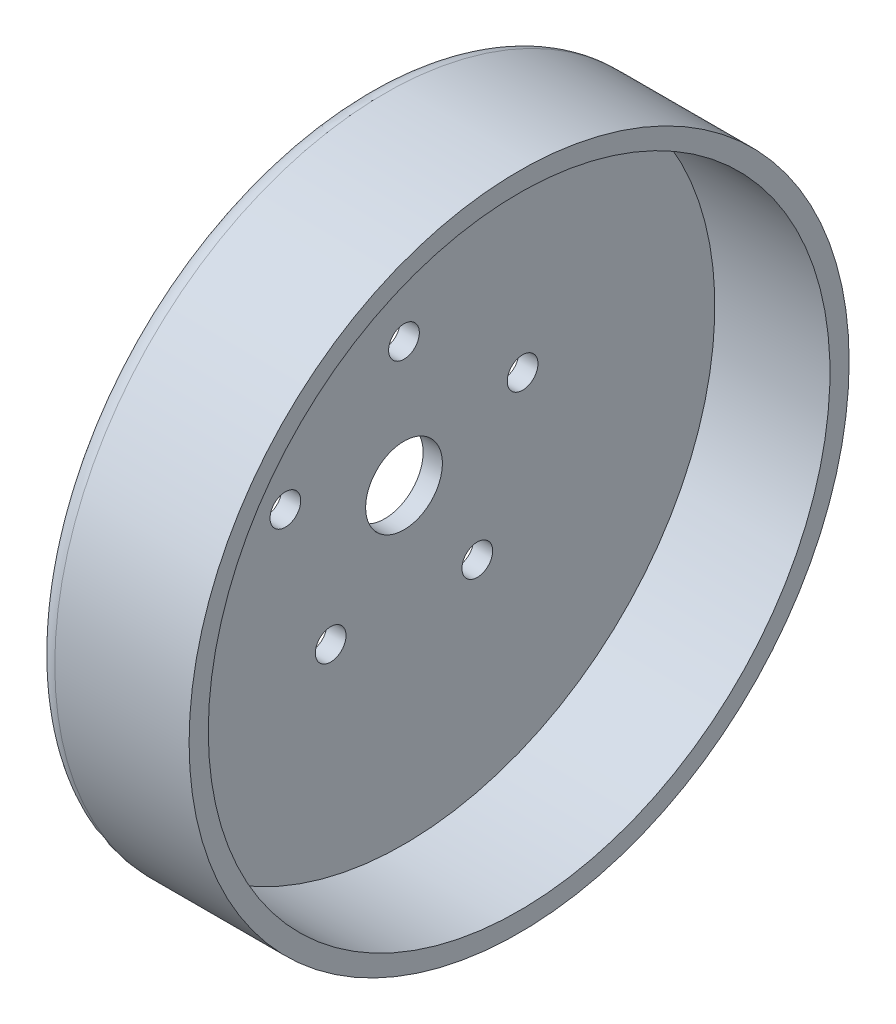
from build123d import *

# Parameters (mm, degrees)
FILLET1_R          = 5
SKETCH2_R          = 45
CUT_EXTRUDE1_DEPTH = 5
SKETCH3_R          = 10
CUT_EXTRUDE2_DEPTH = 41
CUT_EXTRUDE3_REACH = 37
SKETCH4_R          = 4


with BuildPart() as part:
    # Sketch1 → Revolve1 (revolve)
    with BuildSketch(Plane.XY):
        Polygon((0, 0), (0, 81), (30, 81), (30, 86), (-10, 86), (-10, 0), align=None)
    revolve(axis=Axis((-10, 0, 0), (1, 0, 0)))

    # Fillet1
    fillet1_edges = [part.edges().sort_by_distance(p)[0] for p in [
        (-10, -86, 0),
    ]]
    fillet(fillet1_edges, radius=FILLET1_R)

    # Sketch2 → Cut-Extrude1 (cut)
    with BuildSketch(Plane.ZY.offset(10)):
        Circle(SKETCH2_R)
    extrude(amount=-CUT_EXTRUDE1_DEPTH, mode=Mode.SUBTRACT)

    # Sketch3 → Cut-Extrude2 (cut, through all)
    with BuildSketch(Plane.ZY.offset(10)):
        Circle(SKETCH3_R)
    extrude(amount=-CUT_EXTRUDE2_DEPTH, mode=Mode.SUBTRACT)

    # Sketch4 → Cut-Extrude3 (cut, up to next)
    with BuildSketch(Plane.ZY.offset(5), mode=Mode.PRIVATE) as cut_extrude3_sk1:
        with Locations((0, 32.5)):
            Circle(SKETCH4_R)
    cut_extrude3_tool1 = extrude(cut_extrude3_sk1.sketch, amount=-CUT_EXTRUDE3_REACH, mode=Mode.PRIVATE) & part.part
    add(cut_extrude3_tool1.solids().sort_by_distance((-5, 32.5, 0))[0], mode=Mode.SUBTRACT)
    # Sketch4 → Cut-Extrude3 (cut, up to next)
    with BuildSketch(Plane.ZY.offset(5), mode=Mode.PRIVATE) as cut_extrude3_sk2:
        with Locations((30.90933678, 10.043052317)):
            Circle(SKETCH4_R)
    cut_extrude3_tool2 = extrude(cut_extrude3_sk2.sketch, amount=-CUT_EXTRUDE3_REACH, mode=Mode.PRIVATE) & part.part
    add(cut_extrude3_tool2.solids().sort_by_distance((-5, 10.043052, 30.909337))[0], mode=Mode.SUBTRACT)
    # Sketch4 → Cut-Extrude3 (cut, up to next)
    with BuildSketch(Plane.ZY.offset(5), mode=Mode.PRIVATE) as cut_extrude3_sk3:
        with Locations((19.1030207, -26.293052317)):
            Circle(SKETCH4_R)
    cut_extrude3_tool3 = extrude(cut_extrude3_sk3.sketch, amount=-CUT_EXTRUDE3_REACH, mode=Mode.PRIVATE) & part.part
    add(cut_extrude3_tool3.solids().sort_by_distance((-5, -26.293052, 19.103021))[0], mode=Mode.SUBTRACT)
    # Sketch4 → Cut-Extrude3 (cut, up to next)
    with BuildSketch(Plane.ZY.offset(5), mode=Mode.PRIVATE) as cut_extrude3_sk4:
        with Locations((-19.1030207, -26.293052317)):
            Circle(SKETCH4_R)
    cut_extrude3_tool4 = extrude(cut_extrude3_sk4.sketch, amount=-CUT_EXTRUDE3_REACH, mode=Mode.PRIVATE) & part.part
    add(cut_extrude3_tool4.solids().sort_by_distance((-5, -26.293052, -19.103021))[0], mode=Mode.SUBTRACT)
    # Sketch4 → Cut-Extrude3 (cut, up to next)
    with BuildSketch(Plane.ZY.offset(5), mode=Mode.PRIVATE) as cut_extrude3_sk5:
        with Locations((-30.90933678, 10.043052317)):
            Circle(SKETCH4_R)
    cut_extrude3_tool5 = extrude(cut_extrude3_sk5.sketch, amount=-CUT_EXTRUDE3_REACH, mode=Mode.PRIVATE) & part.part
    add(cut_extrude3_tool5.solids().sort_by_distance((-5, 10.043052, -30.909337))[0], mode=Mode.SUBTRACT)


solid = part.part
